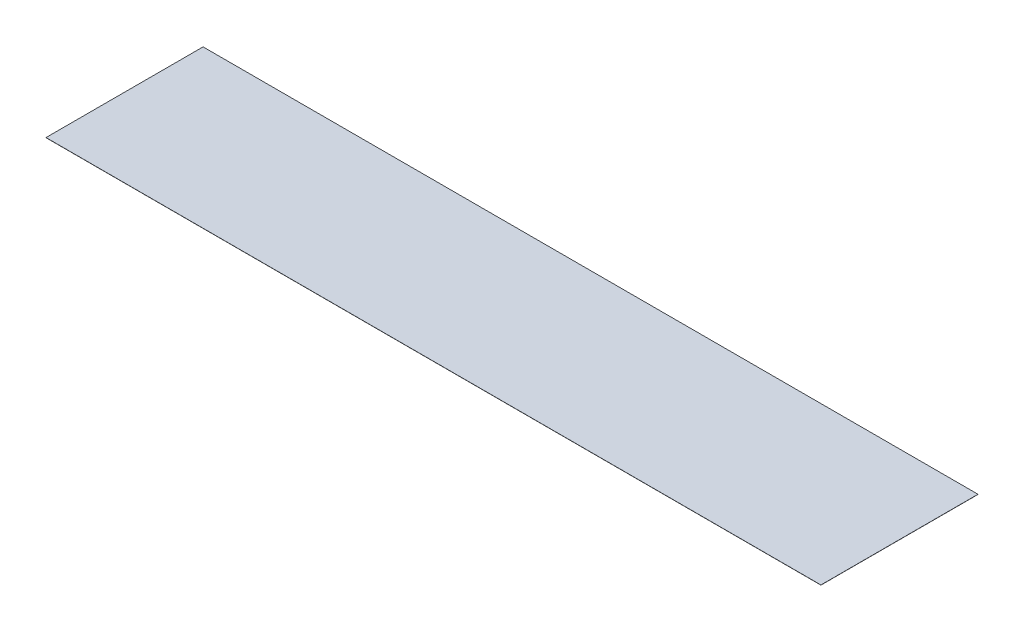
from build123d import *

# Parameters (mm, degrees)
SKETCH1_W           = 22555.2
SKETCH1_H           = 4572
BOSS_EXTRUDE1_DEPTH = 4.7752


with BuildPart() as part:
    # Sketch1 → Boss-Extrude1 (new body)
    with BuildSketch(Plane(origin=(0, 0, 0), x_dir=(1, 0, 0), z_dir=(0, 1, 0))):
        with Locations((11277.6, 2286)):
            Rectangle(SKETCH1_W, SKETCH1_H)
    extrude(amount=BOSS_EXTRUDE1_DEPTH)


solid = part.part
